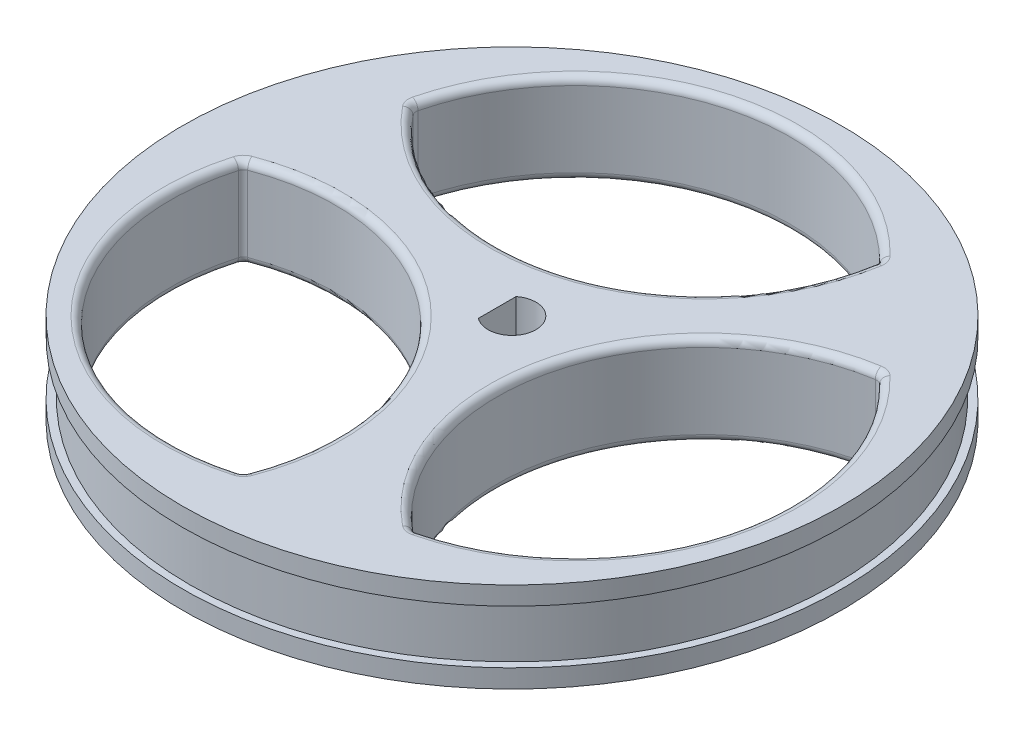
from build123d import *

# Parameters (mm, degrees)
SKETCH2_R                = 22.225
BOSS_EXTRUDE1_DEPTH      = 3.683
SKETCH3_R                = 22.733
BOSS_EXTRUDE2_DEPTH      = 1.27
SKETCH4_R                = 22.733
BOSS_EXTRUDE3_DEPTH      = 1.27
CUT_EXTRUDE1_DEPTH       = 7.223
CUT_EXTRUDE3_DEPTH       = 7.223
FILLET5_R                = 0.508
CIRPATTERN3_COUNT        = 3
FILLET5_OF_CIRPATTERN3_R = 0.508


with BuildPart() as part:
    # Sketch2 → Boss-Extrude1 (new body)
    with BuildSketch(Plane(origin=(0, 0, 0), x_dir=(1, 0, 0), z_dir=(0, 1, 0))):
        Circle(SKETCH2_R)
    extrude(amount=BOSS_EXTRUDE1_DEPTH)

    # Sketch3 → Boss-Extrude2 (add)
    with BuildSketch(Plane(origin=(0, 3.683, 0), x_dir=(1, 0, 0), z_dir=(0, 1, 0))):
        Circle(SKETCH3_R)
    extrude(amount=BOSS_EXTRUDE2_DEPTH)

    # Sketch4 → Boss-Extrude3 (add)
    with BuildSketch(Plane(origin=(0, 0, 0), x_dir=(-1, 0, 0), z_dir=(0, -1, 0))):
        Circle(SKETCH4_R)
    extrude(amount=BOSS_EXTRUDE3_DEPTH)

    # Sketch5 → Cut-Extrude1 (cut, through all)
    with BuildSketch(Plane.XZ.offset(1.27)):
        with BuildLine():
            Line((-1.016, 1.301362747), (-1.016, -1.301362747))
            ThreePointArc((-1.016, -1.301362747), (1.651, 0), (-1.016, 1.301362747))
        make_face()
    extrude(amount=-CUT_EXTRUDE1_DEPTH, mode=Mode.SUBTRACT)

    # Sketch9 → Cut-Extrude3 (cut, through all)
    with BuildSketch(Plane(origin=(0, -1.27, 0), x_dir=(-1, 0, 0), z_dir=(0, -1, 0))):
        with BuildLine():
            ThreePointArc((18.562247706, 0), (14.8545447, -14.853456053), (0, -18.556795097))
            ThreePointArc((0, -18.556795097), (3.147170651, -3.142641985), (18.562247706, 0))
        make_face()
    cut_extrude3 = extrude(amount=-CUT_EXTRUDE3_DEPTH, mode=Mode.SUBTRACT)

    # Fillet5
    fillet5_edges = [part.edges().sort_by_distance(p)[0] for p in [
        (-3.147170651, 4.953, 3.142641985),
        (0, 1.8415, 18.556795097),
        (-14.8545447, 4.953, 14.853456053),
        (-18.562247706, 1.8415, 0),
        (-3.147170651, -1.27, 3.142641985),
        (-14.8545447, -1.27, 14.853456053),
    ]]
    fillet(fillet5_edges, radius=FILLET5_R)

    # CirPattern3: Cut-Extrude3 ×3 about axis
    cirpattern3_axis = Axis((0, 0, 0), (0, 1, 0))
    for i in range(1, CIRPATTERN3_COUNT):
        add(cut_extrude3.rotate(cirpattern3_axis, i * 360 / CIRPATTERN3_COUNT), mode=Mode.SUBTRACT)

    # Fillet5 of CirPattern3
    fillet5_of_cirpattern3_edges = [part.edges().sort_by_distance(p)[0] for p in [
        (4.29519312, 4.953, 1.154208741),
        (16.070655967, 1.8415, -9.278397548),
        (20.290742626, 4.953, 5.437685045),
        (9.281123853, 1.8415, 16.075378065),
        (4.29519312, -1.27, 1.154208741),
        (20.290742626, -1.27, 5.437685045),
        (-1.148022469, 4.953, -4.296850727),
        (-16.070655967, 1.8415, -9.278397548),
        (-5.436197926, 4.953, -20.291141098),
        (9.281123853, 1.8415, -16.075378065),
        (-1.148022469, -1.27, -4.296850727),
        (-5.436197926, -1.27, -20.291141098),
    ]]
    fillet(fillet5_of_cirpattern3_edges, radius=FILLET5_OF_CIRPATTERN3_R)


solid = part.part
